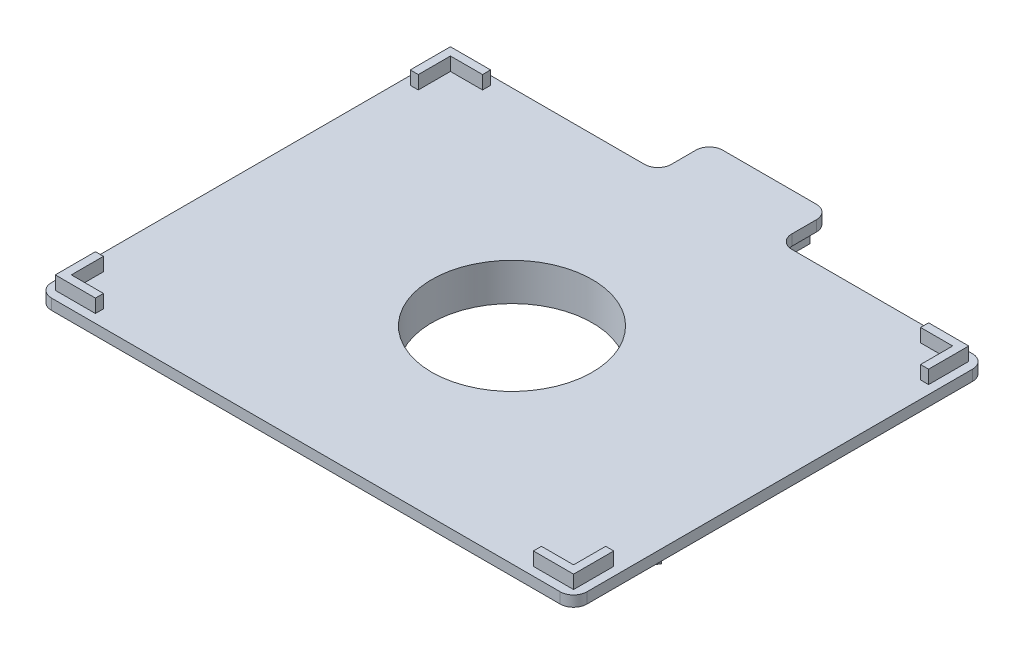
from build123d import *

# Parameters (mm, degrees)
SKETCH1_R           = 30
BOSS_EXTRUDE1_DEPTH = 10
CUT_EXTRUDE1_START  = -106.930254038
SKETCH2_R           = 1.5
CUT_EXTRUDE1_DEPTH  = 183.700508076
CIRPATTERN1_COUNT   = 3
CIRPATTERN1_ANGLE   = 240
FILLET1_R           = 7
SKETCH4_R           = 30
BOSS_EXTRUDE4_DEPTH = 4
BOSS_EXTRUDE5_DEPTH = 5
FILLET4_R           = 5


with BuildPart() as part:
    # Sketch1 → Boss-Extrude1 (new body)
    with BuildSketch(Plane(origin=(0, 0, 0), x_dir=(1, 0, 0), z_dir=(0, 1, 0))):
        with BuildLine():
            Line((-15.08, 76.19839519), (-15.08, 96.19839519))
            Line((-15.08, 96.19839519), (-7.5, 96.19839519))
            Line((-7.5, 96.19839519), (-7.5, 76.19839519))
            Line((-7.5, 76.19839519), (-23.810275834, 47.948168761))
            ThreePointArc((-23.810275834, 47.948168761), (0, 36.19839519), (23.810275834, 47.948168761))
            Line((23.810275834, 47.948168761), (7.5, 76.19839519))
            Line((7.5, 76.19839519), (7.5, 96.19839519))
            Line((7.5, 96.19839519), (15.08, 96.19839519))
            Line((15.08, 96.19839519), (15.08, 76.19839519))
            ThreePointArc((15.08, 76.19839519), (51.866600724, 29.94519589), (73.529745962, -25.039534506))
            Line((73.529745962, -25.039534506), (90.850254038, -35.039534506))
            Line((90.850254038, -35.039534506), (87.060254038, -41.604007067))
            Line((87.060254038, -41.604007067), (69.739745962, -31.604007067))
            Line((69.739745962, -31.604007067), (53.429470128, -3.353780637))
            ThreePointArc((53.429470128, -3.353780637), (31.348729811, -18.099197595), (29.619194295, -44.594388123))
            Line((29.619194295, -44.594388123), (62.239745962, -44.594388123))
            Line((62.239745962, -44.594388123), (79.560254038, -54.594388123))
            Line((79.560254038, -54.594388123), (75.770254038, -61.158860684))
            Line((75.770254038, -61.158860684), (58.449745962, -51.158860684))
            ThreePointArc((58.449745962, -51.158860684), (0, -59.89039178), (-58.449745962, -51.158860684))
            Line((-58.449745962, -51.158860684), (-75.770254038, -61.158860684))
            Line((-75.770254038, -61.158860684), (-79.560254038, -54.594388123))
            Line((-79.560254038, -54.594388123), (-62.239745962, -44.594388123))
            Line((-62.239745962, -44.594388123), (-29.619194295, -44.594388123))
            ThreePointArc((-29.619194295, -44.594388123), (-31.348729811, -18.099197595), (-53.429470128, -3.353780637))
            Line((-53.429470128, -3.353780637), (-69.739745962, -31.604007067))
            Line((-69.739745962, -31.604007067), (-87.060254038, -41.604007067))
            Line((-87.060254038, -41.604007067), (-90.850254038, -35.039534506))
            Line((-90.850254038, -35.039534506), (-73.529745962, -25.039534506))
            ThreePointArc((-73.529745962, -25.039534506), (-51.866600724, 29.94519589), (-15.08, 76.19839519))
        make_face()
        Circle(SKETCH1_R, mode=Mode.SUBTRACT)
    extrude(amount=BOSS_EXTRUDE1_DEPTH)

    # Sketch2 → Cut-Extrude1 (cut)
    with BuildSketch(Plane(origin=(15.08, 0, 0), x_dir=(0, 0, -1), z_dir=(1, 0, 0)).offset(CUT_EXTRUDE1_START)):
        with Locations((86.19839519, 3)):
            Circle(SKETCH2_R)
    cut_extrude1 = extrude(amount=CUT_EXTRUDE1_DEPTH, mode=Mode.SUBTRACT)

    # CirPattern1: Cut-Extrude1 ×3 about axis
    cirpattern1_axis = Axis((0, 10, 0), (0, -1, 0))
    for i in range(1, CIRPATTERN1_COUNT):
        add(cut_extrude1.rotate(cirpattern1_axis, i * CIRPATTERN1_ANGLE / (CIRPATTERN1_COUNT - 1)), mode=Mode.SUBTRACT)

    # Fillet1
    fillet1_edges = [part.edges().sort_by_distance(p)[0] for p in [
        (-69.739745962, 5, 31.604007067),
        (-73.529745962, 5, 25.039534506),
        (-15.08, 5, -76.19839519),
        (-7.5, 5, -76.19839519),
        (-23.810275834, 5, -47.948168761),
        (23.810275834, 5, -47.948168761),
        (7.5, 5, -76.19839519),
        (15.08, 5, -76.19839519),
        (73.529745962, 5, 25.039534506),
        (69.739745962, 5, 31.604007067),
        (53.429470128, 5, 3.353780637),
        (29.619194295, 5, 44.594388123),
        (62.239745962, 5, 44.594388123),
        (58.449745962, 5, 51.158860684),
        (-58.449745962, 5, 51.158860684),
        (-62.239745962, 5, 44.594388123),
        (-29.619194295, 5, 44.594388123),
        (-53.429470128, 5, 3.353780637),
    ]]
    fillet(fillet1_edges, radius=FILLET1_R)

    # Sketch4 → Boss-Extrude4 (add)
    with BuildSketch(Plane(origin=(0, 10, 0), x_dir=(1, 0, 0), z_dir=(0, 1, 0))):
        with BuildLine():
            Line((-95, -77), (95, -77))
            ThreePointArc((95, -77), (98.535533906, -75.535533906), (100, -72))
            Line((100, -72), (100, 72))
            ThreePointArc((100, 72), (98.535533906, 75.535533906), (95, 77))
            Line((95, 77), (-95, 77))
            ThreePointArc((-95, 77), (-98.535533906, 75.535533906), (-100, 72))
            Line((-100, 72), (-100, -72))
            ThreePointArc((-100, -72), (-98.535533906, -75.535533906), (-95, -77))
        make_face()
        Circle(SKETCH4_R, mode=Mode.SUBTRACT)
        with BuildLine():
            Line((-22.5, 77), (22.5, 77))
            Line((22.5, 77), (22.5, 91.19839519))
            ThreePointArc((22.5, 91.19839519), (21.035533906, 94.733929096), (17.5, 96.19839519))
            Line((17.5, 96.19839519), (-17.5, 96.19839519))
            ThreePointArc((-17.5, 96.19839519), (-21.035533906, 94.733929096), (-22.5, 91.19839519))
            Line((-22.5, 91.19839519), (-22.5, 77))
        make_face()
    extrude(amount=BOSS_EXTRUDE4_DEPTH)

    # Sketch5 → Boss-Extrude5 (add)
    with BuildSketch(Plane(origin=(0, 14, 0), x_dir=(1, 0, 0), z_dir=(0, 1, 0))):
        Polygon((-96.8, 73.8), (-81.8, 73.8), (-81.8, 70.8), (-93.8, 70.8), (-93.8, 58.8), (-96.8, 58.8), align=None)
        Polygon((93.8, 70.8), (81.8, 70.8), (81.8, 73.8), (96.8, 73.8), (96.8, 58.8), (93.8, 58.8), align=None)
        Polygon((93.8, -58.8), (93.8, -70.8), (81.8, -70.8), (81.8, -73.8), (96.8, -73.8), (96.8, -58.8), align=None)
        Polygon((-93.8, -58.8), (-96.8, -58.8), (-96.8, -73.8), (-81.8, -73.8), (-81.8, -70.8), (-93.8, -70.8), align=None)
    extrude(amount=BOSS_EXTRUDE5_DEPTH)

    # Fillet4
    fillet4_edges = [part.edges().sort_by_distance(p)[0] for p in [
        (-22.5, 12, -77),
        (22.5, 12, -77),
    ]]
    fillet(fillet4_edges, radius=FILLET4_R)


solid = part.part
